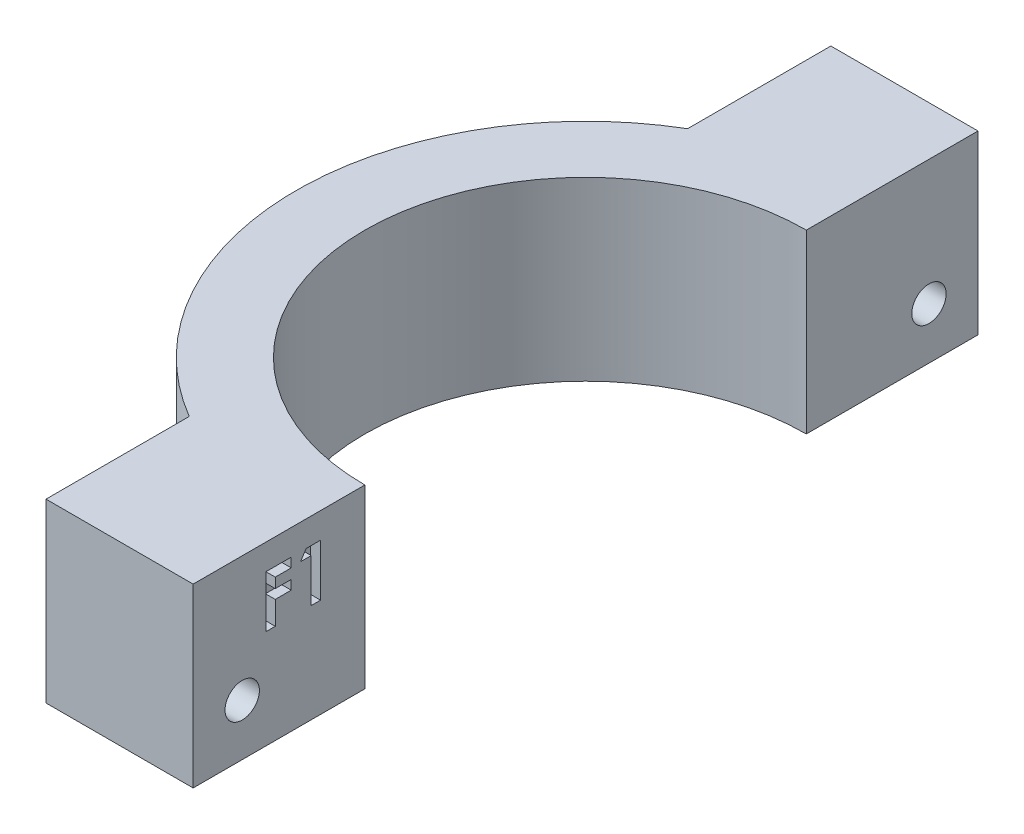
from build123d import *

# Parameters (mm, degrees)
BOSS_EXTRUDE1_DEPTH = 18
SKETCH2_R           = 1.75
CUT_EXTRUDE1_DEPTH  = 30.5
CUT_EXTRUDE2_DEPTH  = 1
CUT_EXTRUDE3_DEPTH  = 5


with BuildPart() as part:
    # Sketch1 → Boss-Extrude1 (new body)
    with BuildSketch(Plane(origin=(0, 0, 0), x_dir=(1, 0, 0), z_dir=(0, 1, 0))):
        with BuildLine():
            ThreePointArc((-16.998275301, 22.028571429), (-24.773162376, 20.985576383), (-31.998275301, 17.93034302))
            ThreePointArc((-31.998275301, 17.93034302), (-46.498275301, -7.471428571), (-31.998275301, -32.873200163))
            ThreePointArc((-31.998275301, -32.873200163), (-24.773162376, -35.928433526), (-16.998275301, -36.971428571))
            Line((-16.998275301, -36.971428571), (-16.998275301, -29.971428571))
            ThreePointArc((-16.998275301, -29.971428571), (-39.498275301, -7.471428571), (-16.998275301, 15.028571429))
            Line((-16.998275301, 15.028571429), (-16.998275301, 22.028571429))
        make_face()
        with BuildLine():
            Line((-16.998275301, 32.528571429), (-31.998275301, 32.528571429))
            Line((-31.998275301, 32.528571429), (-31.998275301, 17.93034302))
            ThreePointArc((-31.998275301, 17.93034302), (-24.773162376, 20.985576383), (-16.998275301, 22.028571429))
            Line((-16.998275301, 22.028571429), (-16.998275301, 32.528571429))
        make_face()
        with BuildLine():
            Line((-31.998275301, -32.873200163), (-31.998275301, -47.471428571))
            Line((-31.998275301, -47.471428571), (-16.998275301, -47.471428571))
            Line((-16.998275301, -47.471428571), (-16.998275301, -36.971428571))
            ThreePointArc((-16.998275301, -36.971428571), (-24.773162376, -35.928433526), (-31.998275301, -32.873200163))
        make_face()
    extrude(amount=BOSS_EXTRUDE1_DEPTH)

    # Sketch2 → Cut-Extrude1 (cut, through all)
    with BuildSketch(Plane(origin=(-16.998275301, 0, 0), x_dir=(0, 0, -1), z_dir=(1, 0, 0))):
        with Locations((-42.471428571, 5.25)):
            Circle(SKETCH2_R)
        with Locations((27.528571429, 5.25)):
            Circle(SKETCH2_R)
    extrude(amount=-CUT_EXTRUDE1_DEPTH, mode=Mode.SUBTRACT)

    # Sketch3 → Cut-Extrude2 (cut)
    with BuildSketch(Plane(origin=(-16.998275301, 0, 0), x_dir=(0, 0, -1), z_dir=(1, 0, 0))):
        Polygon((-40.05243206, 15.382896708), (-37.474440607, 15.382896708), (-37.474440607, 14.433110383), (-39.102645735, 14.433110383), (-39.102645735, 13.415482178), (-37.474440607, 13.415482178), (-37.474440607, 12.465695853), (-39.102645735, 12.465695853), (-39.102645735, 10.091230041), (-40.05243206, 10.091230041), align=None)
        Polygon((-35.957538563, 15.382896708), (-34.489397872, 15.382896708), (-34.489397872, 10.091230041), (-35.439184196, 10.091230041), (-35.439184196, 14.500952263), (-36.524654282, 14.500952263), align=None)
    extrude(amount=-CUT_EXTRUDE2_DEPTH, mode=Mode.SUBTRACT)

    # Sketch4 → Cut-Extrude3 (cut)
    with BuildSketch(Plane.ZY.offset(31.998275301)):
        Polygon((-26.308738524, 2.318218798), (-24.379657977, 4.840515682), (-25.599490881, 7.772296885), (-28.748404333, 8.181781202), (-30.67748488, 5.659484318), (-29.457651976, 2.727703115), align=None)
        Polygon((43.823590255, 2.376849792), (45.635730482, 4.984431264), (44.283568799, 7.857581471), (41.119266888, 8.123150208), (39.307126661, 5.515568736), (40.659288344, 2.642418529), align=None)
    extrude(amount=-CUT_EXTRUDE3_DEPTH, mode=Mode.SUBTRACT)


solid = part.part
